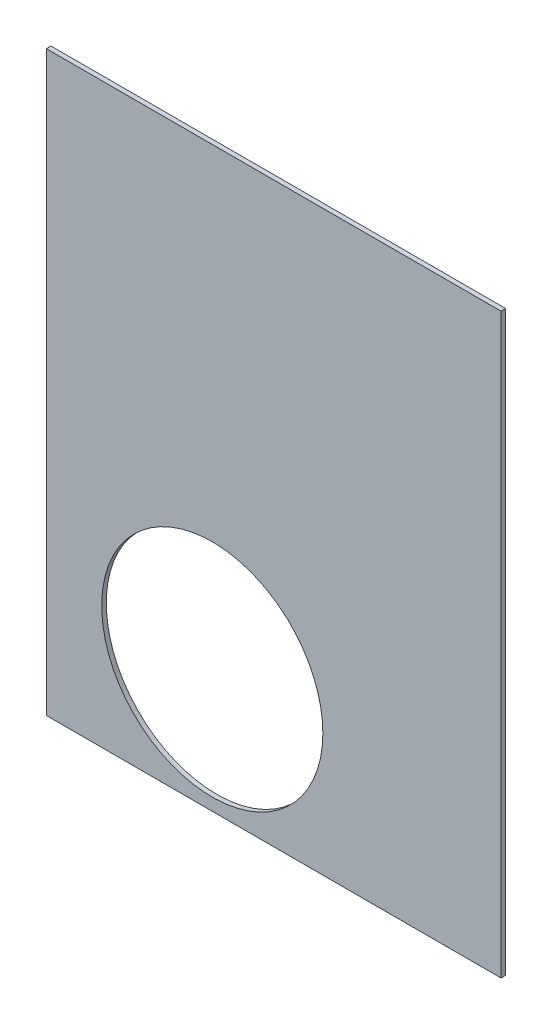
from build123d import *

# Parameters (mm, degrees)
SKETCH1_W           = 74
SKETCH1_H           = 94
BOSS_EXTRUDE1_DEPTH = 0.75
SKETCH3_R           = 18
CUT_EXTRUDE1_DEPTH  = 1.75


with BuildPart() as part:
    # Sketch1 → Boss-Extrude1 (new body)
    with BuildSketch(Plane.XY):
        with Locations((0, 52.5)):
            Rectangle(SKETCH1_W, SKETCH1_H)
    extrude(amount=BOSS_EXTRUDE1_DEPTH)

    # Sketch3 → Cut-Extrude1 (cut, through all)
    with BuildSketch(Plane.XY.offset(0.75)):
        with Locations((-10, 25.5)):
            Circle(SKETCH3_R)
    extrude(amount=-CUT_EXTRUDE1_DEPTH, mode=Mode.SUBTRACT)


solid = part.part
